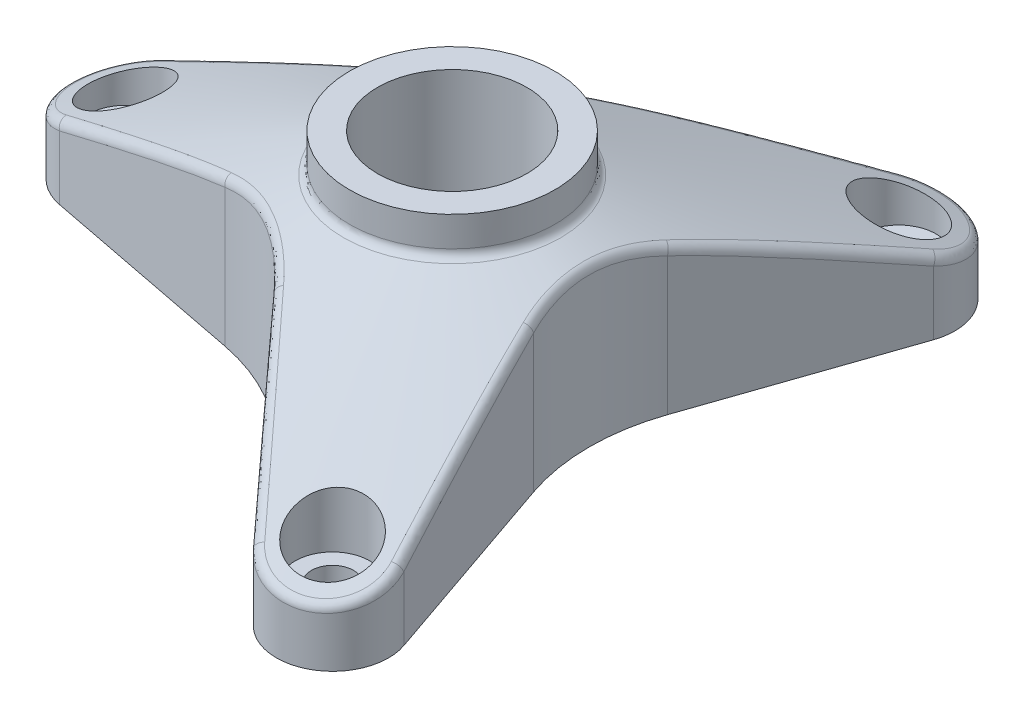
from build123d import *

# Parameters (mm, degrees)
BOSS_EXTRUDE1_DEPTH            = 22
CBORE_FOR_M4_SHCS1_D           = 4.5
CBORE_FOR_M4_SHCS1_CBORE_D     = 8
CBORE_FOR_M4_SHCS1_CBORE_DEPTH = 18
F_16_0_16_DIAMETER_HOLE1_D     = 16
FILLET4_R                      = 1
FILLET5_R                      = 1


with BuildPart() as part:
    # Sketch1 → Boss-Extrude1 (new body)
    with BuildSketch(Plane(origin=(0, 0, 0), x_dir=(1, 0, 0), z_dir=(0, 1, 0))):
        with BuildLine():
            Line((-36.144853972259234, 5.88976310068599), (-14.140453582496708, 10.166985250838051))
            ThreePointArc((-14.140453582496708, 10.166985250838051), (-7.338251480780411, 12.710224403429095), (-1.734640715879256, 17.32948464889584))
            Line((-1.734640715879256, 17.32948464889584), (12.971742518663033, 34.2472433063985))
            ThreePointArc((12.971742518663033, 34.2472433063985), (20.499999999999655, 35.50704155516222), (23.173111453595638, 28.35748020571263))
            Line((23.173111453595638, 28.35748020571263), (15.875094298375691, 7.1624993980575375))
            ThreePointArc((15.875094298375691, 7.1624993980575375), (14.676502961560693, 9.33e-15), (15.875094298375807, -7.162499398057499))
            Line((15.875094298375807, -7.162499398057499), (23.173111453596018, -28.357480205712296))
            ThreePointArc((23.173111453596018, -28.357480205712296), (20.500000000000206, -35.5070415551619), (12.971742518663538, -34.24724330639836))
            Line((12.971742518663538, -34.24724330639836), (-1.7346407158793957, -17.32948464889574))
            ThreePointArc((-1.7346407158793957, -17.32948464889574), (-7.338251480780343, -12.710224403429308), (-14.140453582496292, -10.166985250838374))
            Line((-14.140453582496292, -10.166985250838374), (-36.14485397225931, -5.889763100685976))
            ThreePointArc((-36.14485397225931, -5.889763100685976), (-41.00000000000001, 3.804e-14), (-36.144853972259234, 5.88976310068599))
        make_face()
    extrude(amount=BOSS_EXTRUDE1_DEPTH)

    # CBORE for M4 SHCS1 (through all)
    with Locations(Plane(origin=(-35, 22, 0), x_dir=(0, 0, 1), z_dir=(0, 1, 0))):
        with Locations((0, 0), (30.310889132, 52.5), (-30.310889132, 52.5)):
            CounterBoreHole(CBORE_FOR_M4_SHCS1_D / 2, CBORE_FOR_M4_SHCS1_CBORE_D / 2, CBORE_FOR_M4_SHCS1_CBORE_DEPTH)

    # Sketch3 → Cut-Revolve1 (revolve, cut)
    with BuildSketch(Plane.XY, mode=Mode.PRIVATE) as cut_revolve1_sk:
        Polygon((-11.000000000000004, 25), (-11.000000000000004, 18.12078677505461), (-41.00000000000001, 6), (-41.00000000000001, 31.8877839950516), (-11.000000000000004, 31.8877839950516), align=None)
    revolve(cut_revolve1_sk.sketch.rotate(Axis((-3.47e-15, 25, 0), (1.2e-16, -1, 0)), 155.716132717), axis=Axis((-3.47e-15, 25, 0), (1.2e-16, -1, 0)), mode=Mode.SUBTRACT)

    # Ø16.0 (16) Diameter Hole1 (through all)
    with Locations(Plane.ZX.offset(22)):
        with Locations((0, 0)):
            Hole(F_16_0_16_DIAMETER_HOLE1_D / 2)

    # Fillet4
    fillet4_edges = [part.edges().sort_by_distance(p)[0] for p in [
        (-10.026710212241001, 18.120786775054615, 4.5238349129629025),
    ]]
    fillet(fillet4_edges, radius=FILLET4_R)

    # Fillet5
    fillet5_edges = [part.edges().sort_by_distance(p)[0] for p in [
        (5.6690074980785425, 11.874214301420496, 25.84640765241106),
        (-7.338251481073143, 16.635383159225324, 12.710224403261046),
        (-25.21814937259568, 11.874214301420508, 8.013699318625187),
        (-41, 5.999999999999999, 1.057e-14),
        (-25.218149372595835, 11.87421430142047, -8.013699318625035),
        (-7.338251480488288, 16.635383159225384, -12.71022440359853),
        (5.669007498078356, 11.87421430142047, -25.846407652411184),
        (20.49999999999966, 6.000000000000006, -35.50704155516218),
        (19.549141873998103, 11.87421430198581, -17.832708332278912),
        (14.676502961561374, 16.63538315922539, 3.3769919e-10),
        (19.549141874517314, 11.874214301420498, 17.832708333785902),
        (20.500000000000156, 6.000000000000006, 35.5070415551619),
    ]]
    fillet(fillet5_edges, radius=FILLET5_R)


solid = part.part
